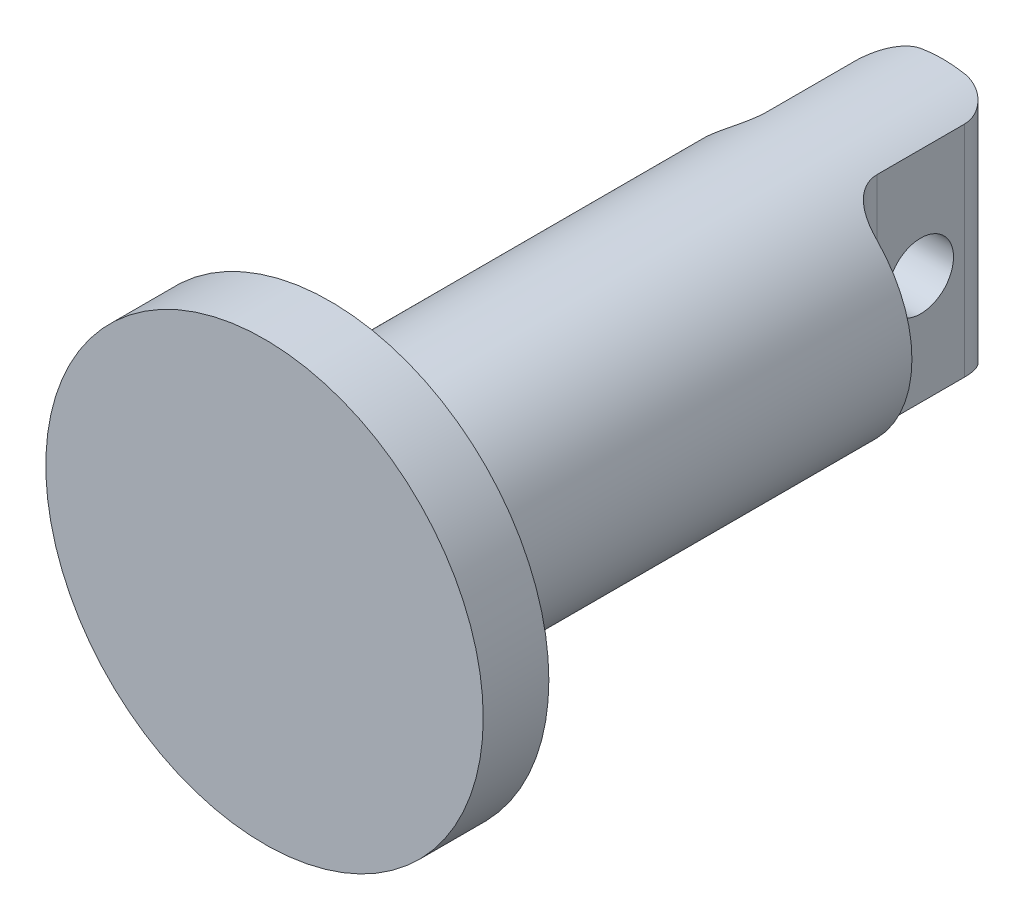
from build123d import *
from OCP.BRepFilletAPI import BRepFilletAPI_MakeFillet

# Parameters (mm, degrees)
SKETCH1_R           = 10
BOSS_EXTRUDE1_DEPTH = 3
SKETCH2_R           = 5.6
BOSS_EXTRUDE2_DEPTH = 28
CUT_EXTRUDE1_DEPTH  = 7
CUT_EXTRUDE2_REACH  = 34.253
SKETCH4_R           = 1.5
FILLET1_R1          = 3
FILLET1_R2          = 1.5


with BuildPart() as part:
    # Sketch1 → Boss-Extrude1 (new body)
    with BuildSketch(Plane.XY):
        Circle(SKETCH1_R)
    extrude(amount=BOSS_EXTRUDE1_DEPTH)

    # Sketch2 → Boss-Extrude2 (add)
    with BuildSketch(Plane(origin=(0, 0, 0), x_dir=(-1, 0, 0), z_dir=(0, 0, -1))):
        Circle(SKETCH2_R)
    extrude(amount=BOSS_EXTRUDE2_DEPTH)

    # Sketch3 → Cut-Extrude1 (cut)
    with BuildSketch(Plane(origin=(0, 0, -28), x_dir=(-1, 0, 0), z_dir=(0, 0, -1))):
        with BuildLine():
            Line((2.5, 0), (2.5, 6.663171691))
            ThreePointArc((2.5, 6.663171691), (8.066213365, -0.537352556), (2.5, -7.737876802))
            Line((2.5, -7.737876802), (2.5, 0))
        make_face()
        with BuildLine():
            Line((-2.5, 0), (-2.5, 6.663171691))
            ThreePointArc((-2.5, 6.663171691), (-7.668145551, -0.537352556), (-2.5, -7.737876802))
            Line((-2.5, -7.737876802), (-2.5, 0))
        make_face()
    extrude(amount=-CUT_EXTRUDE1_DEPTH, mode=Mode.SUBTRACT)

    # Sketch4 → Cut-Extrude2 (cut, up to next)
    with BuildSketch(Plane(origin=(2.5, 0, 0), x_dir=(0, 0, -1), z_dir=(1, 0, 0)), mode=Mode.PRIVATE) as cut_extrude2_sk1:
        with Locations((24.5, 0)):
            Circle(SKETCH4_R)
    cut_extrude2_tool1 = extrude(cut_extrude2_sk1.sketch, amount=-CUT_EXTRUDE2_REACH, mode=Mode.PRIVATE) & part.part
    add(cut_extrude2_tool1.solids().sort_by_distance((2.5, 0, -24.5))[0], mode=Mode.SUBTRACT)

    # Fillet1: one fillet with a radius per group of edges: ONE call of the kernel's fillet builder (fillet() takes one radius for all edges)
    fillet1_edges_1 = [part.edges().sort_by_distance(p)[0] for p in [
        (5.6, 0, 0),
    ]]
    fillet1_edges_2 = [part.edges().sort_by_distance(p)[0] for p in [
        (2.5, 0, -21),
        (-2.5, 0, -21),
        (2.5, 0, -28),
        (-2.5, 0, -28),
    ]]
    fillet1 = BRepFilletAPI_MakeFillet(part.part.solid().wrapped)
    for e in fillet1_edges_1:
        fillet1.Add(FILLET1_R1, e.wrapped)
    for e in fillet1_edges_2:
        fillet1.Add(FILLET1_R2, e.wrapped)
    add(Compound.cast(fillet1.Shape()), mode=Mode.REPLACE)


solid = part.part
